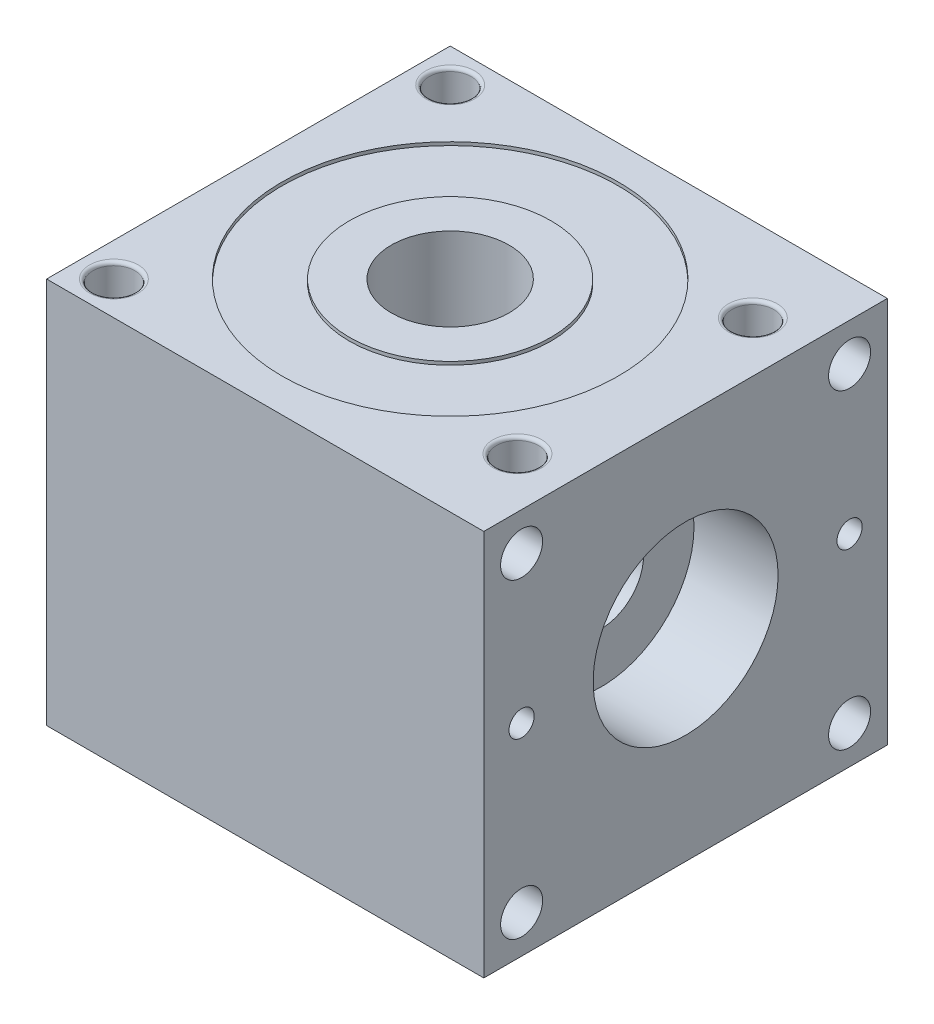
from build123d import *

# Parameters (mm, degrees)
SKETCH1_W          = 82.55
SKETCH1_H          = 76.2
EXTRUDE1_DEPTH     = 73.025
SKETCH2_R          = 10.16
SKETCH2_R_2        = 3.96875
CUT_EXTRUDE1_DEPTH = 73.025
SKETCH5_R          = 20.386166328
CUT_EXTRUDE2_DEPTH = 8.6741
SKETCH6_R          = 3.96875
CUT_EXTRUDE3_DEPTH = 15.875
FILLET1_R          = 0.635
SKETCH3_R          = 31.75
SKETCH3_R_2        = 19.05
CUT_EXTRUDE4_DEPTH = 0.635
SKETCH7_R          = 17.4625
SKETCH7_R_2        = 3.96875
SKETCH7_R_3        = 2.38125
CUT_EXTRUDE5_DEPTH = 15.875
SKETCH8_R          = 7.9375
CUT_EXTRUDE6_DEPTH = 50.8
SKETCH9_R          = 11.1125
CUT_EXTRUDE7_DEPTH = 57.15


with BuildPart() as part:
    # Sketch1 → Extrude1 (new body)
    with BuildSketch(Plane(origin=(0, 0, 0), x_dir=(1, 0, 0), z_dir=(0, 1, 0))):
        with Locations((41.275, -38.1)):
            Rectangle(SKETCH1_W, SKETCH1_H)
    extrude(amount=EXTRUDE1_DEPTH)

    # Sketch2 → Cut-Extrude1 (cut)
    with BuildSketch(Plane(origin=(0, 73.025, 0), x_dir=(-1, 0, 0), z_dir=(0, 1, 0))):
        with Locations((-38.156504372, 38.166240951)):
            Circle(SKETCH2_R)
        with Locations((-6.35, 6.35)):
            Circle(SKETCH2_R_2)
        with Locations((-6.35, 69.84780018)):
            Circle(SKETCH2_R_2)
        with Locations((-73.025, 15.875)):
            Circle(SKETCH2_R_2)
        with Locations((-73.025, 60.325)):
            Circle(SKETCH2_R_2)
    extrude(amount=-CUT_EXTRUDE1_DEPTH, mode=Mode.SUBTRACT)

    # Sketch5 → Cut-Extrude2 (cut)
    with BuildSketch(Plane.XZ):
        with Locations((38.177653641, 38.1)):
            Circle(SKETCH5_R)
    extrude(amount=-CUT_EXTRUDE2_DEPTH, mode=Mode.SUBTRACT)

    # Sketch6 → Cut-Extrude3 (cut)
    with BuildSketch(Plane.ZY):
        with Locations((15.875, 38.1)):
            Circle(SKETCH6_R)
        with Locations((60.325, 38.1)):
            Circle(SKETCH6_R)
    extrude(amount=-CUT_EXTRUDE3_DEPTH, mode=Mode.SUBTRACT)

    # Fillet1
    fillet1_edges = [part.edges().sort_by_distance(p)[0] for p in [
        (10.31875, 0, 6.35),
        (10.31875, 73.025, 6.35),
        (10.31875, 0, 69.84780018),
        (10.31875, 73.025, 69.84780018),
        (76.99375, 0, 15.875),
        (76.99375, 73.025, 15.875),
        (76.99375, 0, 60.325),
        (76.99375, 73.025, 60.325),
        (0, 38.1, 11.90625),
        (0, 38.1, 56.35625),
    ]]
    fillet(fillet1_edges, radius=FILLET1_R)

    # Sketch3 → Cut-Extrude4 (cut)
    with BuildSketch(Plane(origin=(0, 73.025, 0), x_dir=(-1, 0, 0), z_dir=(0, 1, 0))):
        with Locations((-38.1, 38.1)):
            Circle(SKETCH3_R)
        with Locations((-38.1, 38.1)):
            Circle(SKETCH3_R_2, mode=Mode.SUBTRACT)
    extrude(amount=-CUT_EXTRUDE4_DEPTH, mode=Mode.SUBTRACT)

    # Sketch7 → Cut-Extrude5 (cut)
    with BuildSketch(Plane(origin=(82.55, 0, 0), x_dir=(0, 0, -1), z_dir=(1, 0, 0))):
        with Locations((-38.1, 38.1)):
            Circle(SKETCH7_R)
        with Locations((-69.0626, 65.8876)):
            Circle(SKETCH7_R_2)
        with Locations((-7.1374, 65.8876)):
            Circle(SKETCH7_R_2)
        with Locations((-69.0626, 7.137695904)):
            Circle(SKETCH7_R_2)
        with Locations((-7.1374, 7.137695904)):
            Circle(SKETCH7_R_2)
        with Locations((-69.0626, 38.1)):
            Circle(SKETCH7_R_3)
        with Locations((-7.1374, 38.1)):
            Circle(SKETCH7_R_3)
    extrude(amount=-CUT_EXTRUDE5_DEPTH, mode=Mode.SUBTRACT)

    # Sketch8 → Cut-Extrude6 (cut)
    with BuildSketch(Plane(origin=(82.55, 0, 0), x_dir=(0, 0, -1), z_dir=(1, 0, 0))):
        with Locations((-38.1, 38.1)):
            Circle(SKETCH8_R)
    extrude(amount=-CUT_EXTRUDE6_DEPTH, mode=Mode.SUBTRACT)

    # Sketch9 → Cut-Extrude7 (cut)
    with BuildSketch(Plane(origin=(0, 73.025, 0), x_dir=(-1, 0, 0), z_dir=(0, 1, 0))):
        with Locations((-38.1, 38.1)):
            Circle(SKETCH9_R)
    extrude(amount=-CUT_EXTRUDE7_DEPTH, mode=Mode.SUBTRACT)


solid = part.part
